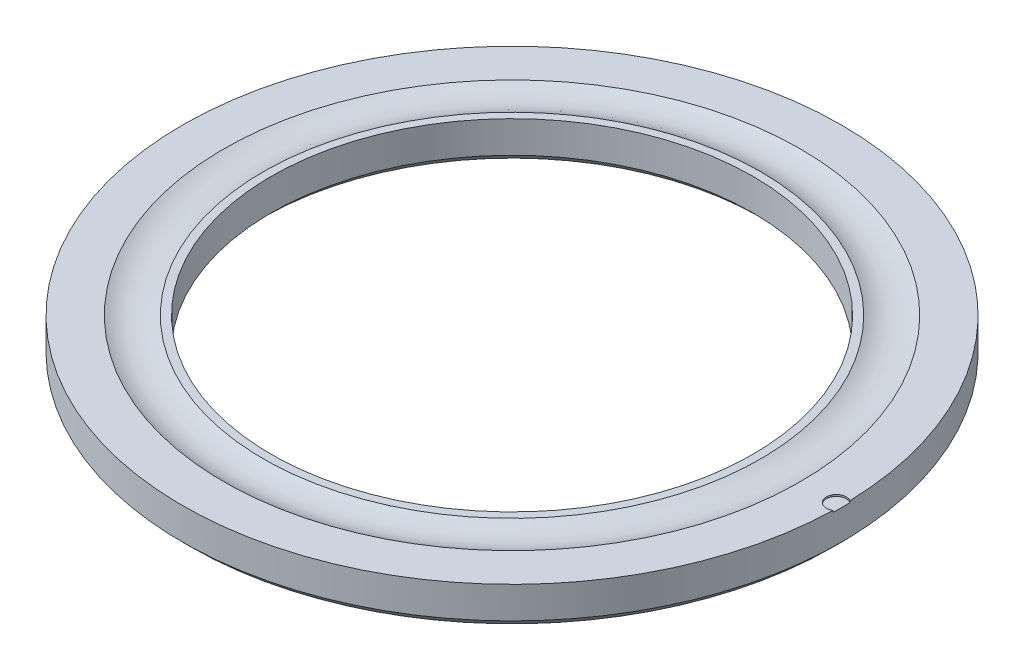
from build123d import *

# Parameters (mm, degrees)
SKETCH3_R          = 1.174710487
CUT_EXTRUDE1_DEPTH = 0.2
CHAMFER1_SIZE      = 1


with BuildPart() as part:
    # Sketch2 → Revolve1 (revolve)
    with BuildSketch(Plane.XY):
        with BuildLine():
            Line((28.5, 0), (39, 0))
            Line((39, 0), (39, 4.75))
            Line((39, 4.75), (34.117811535, 4.75))
            ThreePointArc((34.117811535, 4.75), (31.774779013, 4.167788181), (29.431746492, 4.75))
            Line((29.431746492, 4.75), (28.5, 4.75))
            Line((28.5, 4.75), (28.5, 0))
        make_face()
    revolve(axis=Axis((0, 0, 0), (0, 1, 0)))

    # Sketch3 → Cut-Extrude1 (cut)
    with BuildSketch(Plane(origin=(0, 4.75, 0), x_dir=(1, 0, 0), z_dir=(0, 1, 0))):
        with Locations((38.381757848, 0)):
            Circle(SKETCH3_R)
    extrude(amount=-CUT_EXTRUDE1_DEPTH, mode=Mode.SUBTRACT)

    # Chamfer1
    chamfer1_edges = [part.edges().sort_by_distance(p)[0] for p in [
        (-39, 0, 0),
        (-28.5, 0, 0),
    ]]
    chamfer(chamfer1_edges, length=CHAMFER1_SIZE)


solid = part.part
